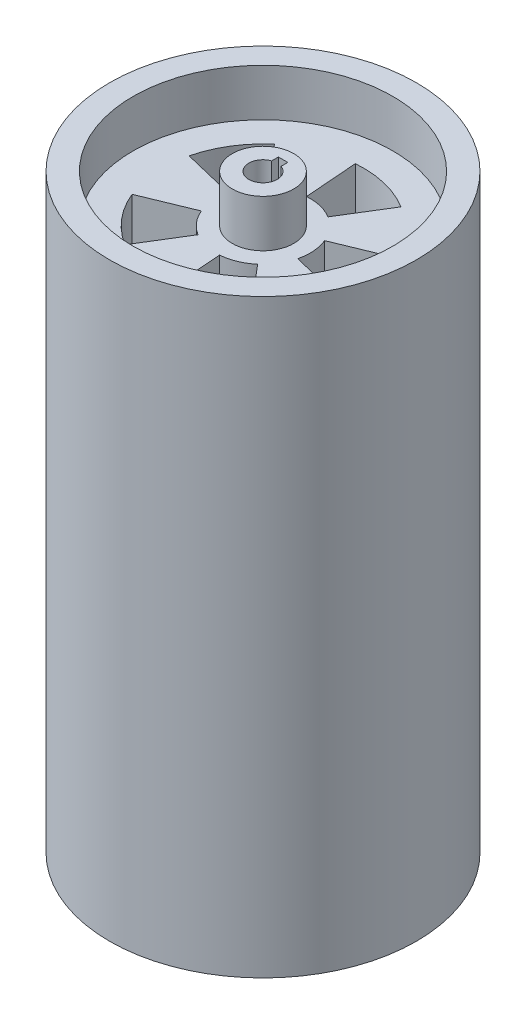
from build123d import *

# Parameters (mm, degrees)
SKETCH1_R           = 65
SKETCH1_R_2         = 55
BOSS_EXTRUDE1_DEPTH = 250
BOSS_EXTRUDE2_START = 20
SKETCH3_R           = 55
SKETCH3_R_2         = 13
BOSS_EXTRUDE2_DEPTH = 20
BOSS_EXTRUDE3_START = 210
SKETCH3_5_R         = 55
SKETCH3_5_R_2       = 13
BOSS_EXTRUDE3_DEPTH = 20
BOSS_EXTRUDE4_START = 20
SKETCH3_7_R         = 13
SKETCH3_7_R_2       = 6.5
BOSS_EXTRUDE4_DEPTH = 210
SKETCH3_10_R        = 13
BOSS_EXTRUDE5_DEPTH = 20
BOSS_EXTRUDE6_START = 230
SKETCH3_11_R        = 13
BOSS_EXTRUDE6_DEPTH = 20


with BuildPart() as part:
    # Sketch1 → Boss-Extrude1 (new body)
    with BuildSketch(Plane(origin=(0, 0, 0), x_dir=(1, 0, 0), z_dir=(0, 1, 0))):
        Circle(SKETCH1_R)
        Circle(SKETCH1_R_2, mode=Mode.SUBTRACT)
    extrude(amount=BOSS_EXTRUDE1_DEPTH)

    # Sketch3 → Boss-Extrude2 (add)
    with BuildSketch(Plane(origin=(0, 0, 0), x_dir=(1, 0, 0), z_dir=(0, 1, 0)).offset(BOSS_EXTRUDE2_START)):
        Circle(SKETCH3_R)
        with BuildLine():
            ThreePointArc((1.527466732, -19.941585829), (7.614996105, -18.493561969), (12.957116602, -15.235259412))
            Line((12.957116602, -15.235259412), (27.53387278, -32.374926251))
            ThreePointArc((27.53387278, -32.374926251), (16.181866723, -39.298819185), (3.245866806, -42.375869887))
            Line((3.245866806, -42.375869887), (1.527466732, -19.941585829))
        make_face(mode=Mode.SUBTRACT)
        with BuildLine():
            ThreePointArc((-18.493561969, -7.614996105), (-15.235259412, -12.957116602), (-10.485623513, -17.030904249))
            Line((-10.485623513, -17.030904249), (-22.281949965, -36.190671529))
            ThreePointArc((-22.281949965, -36.190671529), (-32.374926251, -27.53387278), (-39.298819185, -16.181866723))
            Line((-39.298819185, -16.181866723), (-18.493561969, -7.614996105))
        make_face(mode=Mode.SUBTRACT)
        with BuildLine():
            ThreePointArc((-12.957116602, 15.235259412), (-17.030904249, 10.485623513), (-19.437588327, 4.709581727))
            Line((-19.437588327, 4.709581727), (-41.304875194, 10.00786117))
            ThreePointArc((-41.304875194, 10.00786117), (-36.190671529, 22.281949965), (-27.53387278, 32.374926251))
            Line((-27.53387278, 32.374926251), (-12.957116602, 15.235259412))
        make_face(mode=Mode.SUBTRACT)
        with BuildLine():
            ThreePointArc((10.485623513, 17.030904249), (4.709581727, 19.437588327), (-1.527466732, 19.941585829))
            Line((-1.527466732, 19.941585829), (-3.245866806, 42.375869887))
            ThreePointArc((-3.245866806, 42.375869887), (10.00786117, 41.304875194), (22.281949965, 36.190671529))
            Line((22.281949965, 36.190671529), (10.485623513, 17.030904249))
        make_face(mode=Mode.SUBTRACT)
        with BuildLine():
            Line((18.493561969, 7.614996105), (39.298819185, 16.181866723))
            ThreePointArc((39.298819185, 16.181866723), (42.375869887, 3.245866806), (41.304875194, -10.00786117))
            Line((41.304875194, -10.00786117), (19.437588327, -4.709581727))
            ThreePointArc((19.437588327, -4.709581727), (19.941585829, 1.527466732), (18.493561969, 7.614996105))
        make_face(mode=Mode.SUBTRACT)
        Circle(SKETCH3_R_2, mode=Mode.SUBTRACT)
    extrude(amount=BOSS_EXTRUDE2_DEPTH)

    # Sketch3_5 → Boss-Extrude3 (add)
    with BuildSketch(Plane(origin=(0, 0, 0), x_dir=(1, 0, 0), z_dir=(0, 1, 0)).offset(BOSS_EXTRUDE3_START)):
        Circle(SKETCH3_5_R)
        with BuildLine():
            ThreePointArc((1.527466732, -19.941585829), (7.614996105, -18.493561969), (12.957116602, -15.235259412))
            Line((12.957116602, -15.235259412), (27.53387278, -32.374926251))
            ThreePointArc((27.53387278, -32.374926251), (16.181866723, -39.298819185), (3.245866806, -42.375869887))
            Line((3.245866806, -42.375869887), (1.527466732, -19.941585829))
        make_face(mode=Mode.SUBTRACT)
        with BuildLine():
            ThreePointArc((-18.493561969, -7.614996105), (-15.235259412, -12.957116602), (-10.485623513, -17.030904249))
            Line((-10.485623513, -17.030904249), (-22.281949965, -36.190671529))
            ThreePointArc((-22.281949965, -36.190671529), (-32.374926251, -27.53387278), (-39.298819185, -16.181866723))
            Line((-39.298819185, -16.181866723), (-18.493561969, -7.614996105))
        make_face(mode=Mode.SUBTRACT)
        with BuildLine():
            ThreePointArc((-12.957116602, 15.235259412), (-17.030904249, 10.485623513), (-19.437588327, 4.709581727))
            Line((-19.437588327, 4.709581727), (-41.304875194, 10.00786117))
            ThreePointArc((-41.304875194, 10.00786117), (-36.190671529, 22.281949965), (-27.53387278, 32.374926251))
            Line((-27.53387278, 32.374926251), (-12.957116602, 15.235259412))
        make_face(mode=Mode.SUBTRACT)
        with BuildLine():
            ThreePointArc((10.485623513, 17.030904249), (4.709581727, 19.437588327), (-1.527466732, 19.941585829))
            Line((-1.527466732, 19.941585829), (-3.245866806, 42.375869887))
            ThreePointArc((-3.245866806, 42.375869887), (10.00786117, 41.304875194), (22.281949965, 36.190671529))
            Line((22.281949965, 36.190671529), (10.485623513, 17.030904249))
        make_face(mode=Mode.SUBTRACT)
        with BuildLine():
            Line((18.493561969, 7.614996105), (39.298819185, 16.181866723))
            ThreePointArc((39.298819185, 16.181866723), (42.375869887, 3.245866806), (41.304875194, -10.00786117))
            Line((41.304875194, -10.00786117), (19.437588327, -4.709581727))
            ThreePointArc((19.437588327, -4.709581727), (19.941585829, 1.527466732), (18.493561969, 7.614996105))
        make_face(mode=Mode.SUBTRACT)
        Circle(SKETCH3_5_R_2, mode=Mode.SUBTRACT)
    extrude(amount=BOSS_EXTRUDE3_DEPTH)

    # Sketch3_7 → Boss-Extrude4 (add)
    with BuildSketch(Plane(origin=(0, 0, 0), x_dir=(1, 0, 0), z_dir=(0, 1, 0)).offset(BOSS_EXTRUDE4_START)):
        Circle(SKETCH3_7_R)
        Circle(SKETCH3_7_R_2, mode=Mode.SUBTRACT)
    extrude(amount=BOSS_EXTRUDE4_DEPTH)

    # Sketch3_10 → Boss-Extrude5 (add)
    with BuildSketch(Plane(origin=(0, 0, 0), x_dir=(1, 0, 0), z_dir=(0, 1, 0))):
        Circle(SKETCH3_10_R)
        with BuildLine():
            ThreePointArc((2, 5.656854249), (0, -6), (-2, 5.656854249))
            Line((-2, 5.656854249), (-2, 8.5))
            Line((-2, 8.5), (2, 8.5))
            Line((2, 8.5), (2, 5.656854249))
        make_face(mode=Mode.SUBTRACT)
    extrude(amount=BOSS_EXTRUDE5_DEPTH)

    # Sketch3_11 → Boss-Extrude6 (add)
    with BuildSketch(Plane(origin=(0, 0, 0), x_dir=(1, 0, 0), z_dir=(0, 1, 0)).offset(BOSS_EXTRUDE6_START)):
        Circle(SKETCH3_11_R)
        with BuildLine():
            ThreePointArc((2, 5.656854249), (0, -6), (-2, 5.656854249))
            Line((-2, 5.656854249), (-2, 8.5))
            Line((-2, 8.5), (2, 8.5))
            Line((2, 8.5), (2, 5.656854249))
        make_face(mode=Mode.SUBTRACT)
    extrude(amount=BOSS_EXTRUDE6_DEPTH)


solid = part.part
